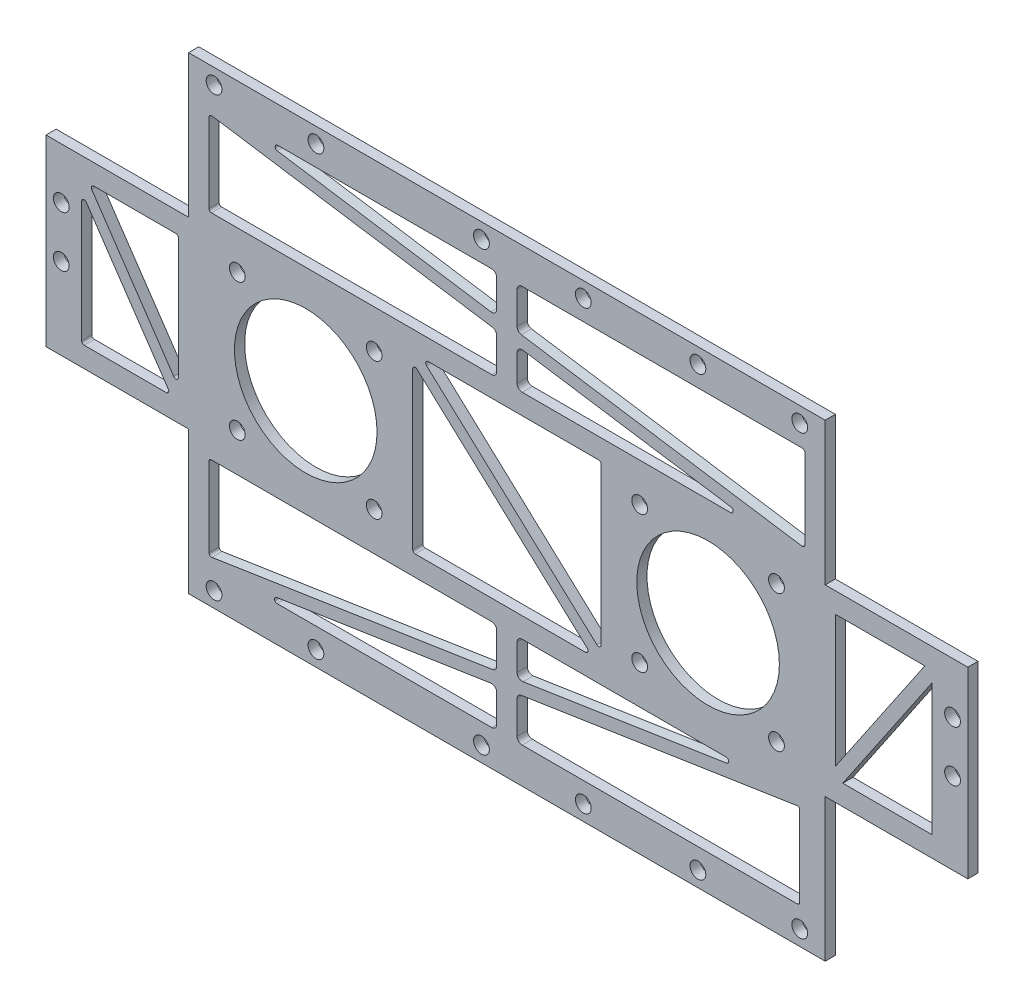
from build123d import *

# Parameters (mm, degrees)
SKETCH_1_R      = 1.55
SKETCH_1_R_2    = 14
EXTRUDE_1_DEPTH = 2


with BuildPart() as part:
    # 草图1 → 凸台-拉伸1 (new body)
    with BuildSketch(Plane.XY):
        Polygon((-90.5, 18), (-90.5, -18), (-62.5, -18), (-62.5, -46), (62.5, -46), (62.5, -18), (90.5, -18), (90.5, 18), (62.5, 18), (62.5, 46), (-62.5, 46), (-62.5, 18), align=None)
        with Locations((-52.935028843, -13.435028843)):
            Circle(SKETCH_1_R, mode=Mode.SUBTRACT)
        with Locations((-52.935028843, 13.435028843)):
            Circle(SKETCH_1_R, mode=Mode.SUBTRACT)
        with Locations((-26.064971157, -13.435028843)):
            Circle(SKETCH_1_R, mode=Mode.SUBTRACT)
        with Locations((-26.064971157, 13.435028843)):
            Circle(SKETCH_1_R, mode=Mode.SUBTRACT)
        with Locations((-39.5, 0)):
            Circle(SKETCH_1_R_2, mode=Mode.SUBTRACT)
        with Locations((39.5, 0)):
            Circle(SKETCH_1_R_2, mode=Mode.SUBTRACT)
        with Locations((57.5, -43)):
            Circle(SKETCH_1_R, mode=Mode.SUBTRACT)
        with Locations((37.5, -43)):
            Circle(SKETCH_1_R, mode=Mode.SUBTRACT)
        with Locations((-57.5, -43)):
            Circle(SKETCH_1_R, mode=Mode.SUBTRACT)
        with Locations((-37.5, -43)):
            Circle(SKETCH_1_R, mode=Mode.SUBTRACT)
        with Locations((-57.5, 43)):
            Circle(SKETCH_1_R, mode=Mode.SUBTRACT)
        with Locations((-37.5, 43)):
            Circle(SKETCH_1_R, mode=Mode.SUBTRACT)
        with Locations((37.5, 43)):
            Circle(SKETCH_1_R, mode=Mode.SUBTRACT)
        with Locations((57.5, 43)):
            Circle(SKETCH_1_R, mode=Mode.SUBTRACT)
        with Locations((15, -43)):
            Circle(SKETCH_1_R, mode=Mode.SUBTRACT)
        with Locations((-5, -43)):
            Circle(SKETCH_1_R, mode=Mode.SUBTRACT)
        with Locations((-5, 43)):
            Circle(SKETCH_1_R, mode=Mode.SUBTRACT)
        with Locations((15, 43)):
            Circle(SKETCH_1_R, mode=Mode.SUBTRACT)
        with Locations((-87.5, 8)):
            Circle(SKETCH_1_R, mode=Mode.SUBTRACT)
        with Locations((-87.5, -2)):
            Circle(SKETCH_1_R, mode=Mode.SUBTRACT)
        with Locations((87.5, 8)):
            Circle(SKETCH_1_R, mode=Mode.SUBTRACT)
        with Locations((87.5, -2)):
            Circle(SKETCH_1_R, mode=Mode.SUBTRACT)
        with Locations((26.064971157, 13.435028843)):
            Circle(SKETCH_1_R, mode=Mode.SUBTRACT)
        with Locations((52.935028843, 13.435028843)):
            Circle(SKETCH_1_R, mode=Mode.SUBTRACT)
        with Locations((52.935028843, -13.435028843)):
            Circle(SKETCH_1_R, mode=Mode.SUBTRACT)
        with Locations((26.064971157, -13.435028843)):
            Circle(SKETCH_1_R, mode=Mode.SUBTRACT)
        with BuildLine():
            Line((-81.106273476, 14), (-65, 14))
            ThreePointArc((-65, 14), (-64.646446609, 13.853553391), (-64.5, 13.5))
            Line((-64.5, 13.5), (-64.5, -10.235560912))
            ThreePointArc((-64.5, -10.235560912), (-64.853147938, -10.713509101), (-65.413737887, -10.516311621))
            Line((-65.413737887, -10.516311621), (-81.520011363, 13.219249291))
            ThreePointArc((-81.520011363, 13.219249291), (-81.548073971, 13.734120317), (-81.106273476, 14))
        make_face(mode=Mode.SUBTRACT)
        with BuildLine():
            Line((-66.893726524, -14), (-83, -14))
            ThreePointArc((-83, -14), (-83.353553391, -13.853553391), (-83.5, -13.5))
            Line((-83.5, -13.5), (-83.5, 10.235560912))
            ThreePointArc((-83.5, 10.235560912), (-83.146852062, 10.713509101), (-82.586262113, 10.516311621))
            Line((-82.586262113, 10.516311621), (-66.479988637, -13.219249291))
            ThreePointArc((-66.479988637, -13.219249291), (-66.451926029, -13.734120317), (-66.893726524, -14))
        make_face(mode=Mode.SUBTRACT)
        with BuildLine():
            Line((-45.012081811, 39), (-3, 39))
            ThreePointArc((-3, 39), (-2.292893219, 38.707106781), (-2, 38))
            Line((-2, 38), (-2, 32.601058551))
            ThreePointArc((-2, 32.601058551), (-2.3483514, 31.842537554), (-3.150708205, 31.61248026))
            Line((-3.150708205, 31.61248026), (-45.087435913, 38.005710855))
            ThreePointArc((-45.087435913, 38.005710855), (-45.510652053, 38.537785098), (-45.012081811, 39))
        make_face(mode=Mode.SUBTRACT)
        with BuildLine():
            Line((58.5, 38.5), (58.5, 22.795865962))
            ThreePointArc((58.5, 22.795865962), (58.3258243, 22.416605463), (57.924645897, 22.301576816))
            Line((57.924645897, 22.301576816), (2.849291795, 30.697783629))
            ThreePointArc((2.849291795, 30.697783629), (2.241479003, 31.03471332), (2, 31.686361919))
            Line((2, 31.686361919), (2, 38))
            ThreePointArc((2, 38), (2.292893219, 38.707106781), (3, 39))
            Line((3, 39), (58, 39))
            ThreePointArc((58, 39), (58.353553391, 38.853553391), (58.5, 38.5))
        make_face(mode=Mode.SUBTRACT)
        with BuildLine():
            Line((43.940148136, 21), (3, 21))
            ThreePointArc((3, 21), (2.292893219, 21.292893219), (2, 22))
            Line((2, 22), (2, 27.235525762))
            ThreePointArc((2, 27.235525762), (2.3483514, 27.994046759), (3.150708205, 28.224104053))
            Line((3.150708205, 28.224104053), (44.015502239, 21.994289145))
            ThreePointArc((44.015502239, 21.994289145), (44.438718378, 21.462214902), (43.940148136, 21))
        make_face(mode=Mode.SUBTRACT)
        with BuildLine():
            Line((-58.5, 21.5), (-58.5, 37.040718351))
            ThreePointArc((-58.5, 37.040718351), (-58.3258243, 37.41997885), (-57.924645897, 37.535007497))
            Line((-57.924645897, 37.535007497), (-2.849291795, 29.138800685))
            ThreePointArc((-2.849291795, 29.138800685), (-2.241479003, 28.801870993), (-2, 28.150222394))
            Line((-2, 28.150222394), (-2, 22))
            ThreePointArc((-2, 22), (-2.292893219, 21.292893219), (-3, 21))
            Line((-3, 21), (-58, 21))
            ThreePointArc((-58, 21), (-58.353553391, 21.146446609), (-58.5, 21.5))
        make_face(mode=Mode.SUBTRACT)
        with BuildLine():
            Line((-58, -21), (-3, -21))
            ThreePointArc((-3, -21), (-2.292893219, -21.292893219), (-2, -22))
            Line((-2, -22), (-2, -28.076121659))
            ThreePointArc((-2, -28.076121659), (-2.24106459, -28.72728757), (-2.848034087, -29.064507394))
            Line((-2.848034087, -29.064507394), (-57.924017044, -37.532529251))
            ThreePointArc((-57.924017044, -37.532529251), (-58.325582956, -37.417804089), (-58.5, -37.038336384))
            Line((-58.5, -37.038336384), (-58.5, -21.5))
            ThreePointArc((-58.5, -21.5), (-58.353553391, -21.146446609), (-58, -21))
        make_face(mode=Mode.SUBTRACT)
        with BuildLine():
            Line((57.5, -22.796852072), (57.5, -38.5))
            ThreePointArc((57.5, -38.5), (57.353553391, -38.853553391), (57, -39))
            Line((57, -39), (3, -39))
            ThreePointArc((3, -39), (2.292893219, -38.707106781), (2, -38))
            Line((2, -38), (2, -31.605315172))
            ThreePointArc((2, -31.605315172), (2.24106459, -30.954149261), (2.848034087, -30.616929437))
            Line((2.848034087, -30.616929437), (56.924017044, -22.302659205))
            ThreePointArc((56.924017044, -22.302659205), (57.325582956, -22.417384367), (57.5, -22.796852072))
        make_face(mode=Mode.SUBTRACT)
        Polygon((64.5, 14), (82.049806487, 14), (64.5, -11.862872718), align=None, mode=Mode.SUBTRACT)
        Polygon((83.5, 11.862872718), (83.5, -14), (65.950193513, -14), align=None, mode=Mode.SUBTRACT)
        with BuildLine():
            Line((-15.443413448, 17), (18, 17))
            ThreePointArc((18, 17), (18.353553391, 16.853553391), (18.5, 16.5))
            Line((18.5, 16.5), (18.5, -14.23178533))
            ThreePointArc((18.5, -14.23178533), (18.201051831, -14.689582405), (17.661687355, -14.599949091))
            Line((17.661687355, -14.599949091), (-15.781726092, 16.13183624))
            ThreePointArc((-15.781726092, 16.13183624), (-15.909289976, 16.681546302), (-15.443413448, 17))
        make_face(mode=Mode.SUBTRACT)
        with BuildLine():
            Line((15.443413448, -17), (-18, -17))
            ThreePointArc((-18, -17), (-18.353553391, -16.853553391), (-18.5, -16.5))
            Line((-18.5, -16.5), (-18.5, 14.23178533))
            ThreePointArc((-18.5, 14.23178533), (-18.201051831, 14.689582405), (-17.661687355, 14.599949091))
            Line((-17.661687355, 14.599949091), (15.781726092, -16.13183624))
            ThreePointArc((15.781726092, -16.13183624), (15.909289976, -16.681546302), (15.443413448, -17))
        make_face(mode=Mode.SUBTRACT)
        with BuildLine():
            Line((2, -22), (2, -27.153611911))
            ThreePointArc((2, -27.153611911), (2.348834089, -27.912547321), (3.151965913, -28.141997647))
            Line((3.151965913, -28.141997647), (43.137265542, -21.994192868))
            ThreePointArc((43.137265542, -21.994192868), (43.559828689, -21.461897728), (43.061282586, -21))
            Line((43.061282586, -21), (3, -21))
            ThreePointArc((3, -21), (2.292893219, -21.292893219), (2, -22))
        make_face(mode=Mode.SUBTRACT)
        with BuildLine():
            Line((-2, -38), (-2, -32.52782492))
            ThreePointArc((-2, -32.52782492), (-2.348834089, -31.76888951), (-3.151965913, -31.539439185))
            Line((-3.151965913, -31.539439185), (-45.209199217, -38.005807132))
            ThreePointArc((-45.209199217, -38.005807132), (-45.631762364, -38.538102272), (-45.133216261, -39))
            Line((-45.133216261, -39), (-3, -39))
            ThreePointArc((-3, -39), (-2.292893219, -38.707106781), (-2, -38))
        make_face(mode=Mode.SUBTRACT)
    extrude(amount=EXTRUDE_1_DEPTH)


solid = part.part
